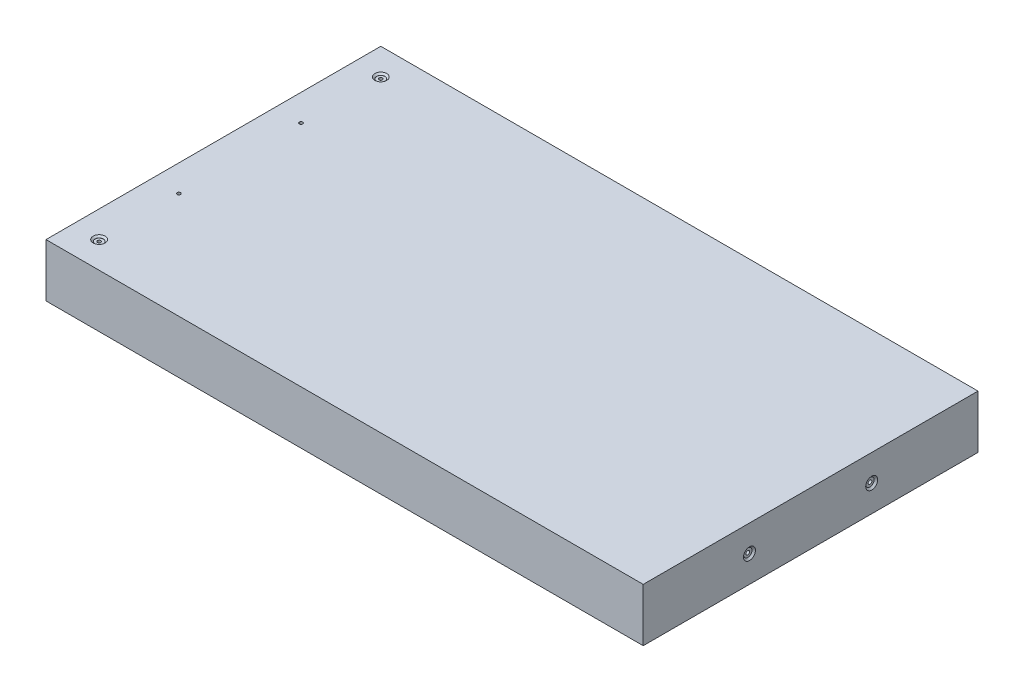
from build123d import *

# Parameters (mm, degrees)
SKETCH1_W                                   = 285.4
SKETCH1_H                                   = 160
BOSS_EXTRUDE1_DEPTH                         = 25.4
CBORE_FOR_0_BINDING_HEAD_MACHINE_SC_2_COUNT = 2
CBORE_FOR_0_BINDING_HEAD_MACHINE_SC_2_PITCH = 58.4
CBORE_FOR_0_BINDING_HEAD_MACHINE_SC_3_COUNT = 2
CBORE_FOR_0_BINDING_HEAD_MACHINE_SC_3_PITCH = 134.6
CBORE_FOR_0_BINDING_HEAD_MACHINE_SC_4_COUNT = 2
CBORE_FOR_0_BINDING_HEAD_MACHINE_SC_4_PITCH = 58.4


with BuildPart() as part:
    # Sketch1 → Boss-Extrude1 (new body)
    with BuildSketch(Plane(origin=(0, 0, 0), x_dir=(1, 0, 0), z_dir=(0, 1, 0))):
        Rectangle(SKETCH1_W, SKETCH1_H)
    extrude(amount=BOSS_EXTRUDE1_DEPTH)

    # Sketch3 → CBORE for #0 Binding Head Machine Screw3 (revolve, cut)
    with BuildSketch(Plane(origin=(142.7, 12.7, 29.2), x_dir=(0, 0, -1), z_dir=(0, 1, 0))):
        Polygon((0, 0), (0, 30.53416509), (0.889, 30), (0.889, 0.8128), (1.98501, 0.8128), (1.98501, 0.87249), (2.8575, 0), align=None)
    cbore_for_0_binding_head_machine_screw3 = revolve(axis=Axis((149.05, 12.7, 29.2), (-1, 0, 0)), mode=Mode.SUBTRACT)

    # CBORE for _0 Binding Head Machine Sc 2: CBORE for #0 Binding Head Machine Screw3 ×2
    with Locations(*[(0, 0, -i * CBORE_FOR_0_BINDING_HEAD_MACHINE_SC_2_PITCH) for i in range(1, CBORE_FOR_0_BINDING_HEAD_MACHINE_SC_2_COUNT)]):
        add(cbore_for_0_binding_head_machine_screw3, mode=Mode.SUBTRACT)

    # Sketch7 → CBORE for #0 Binding Head Machine Screw1 (revolve, cut)
    with BuildSketch(Plane(origin=(-130, 25.4, 67.3), x_dir=(0, 0, 1), z_dir=(1, 0, 0))):
        Polygon((0, 0), (0, 25.4), (0.80645, 25.4), (0.80645, 0.8128), (1.98501, 0.8128), (1.98501, 0.732106037), (2.8575, 0), align=None)
    cbore_for_0_binding_head_machine_screw1 = revolve(axis=Axis((-130, 31.75, 67.3), (0, -1, 0)), mode=Mode.SUBTRACT)

    # CBORE for _0 Binding Head Machine Sc 3: CBORE for #0 Binding Head Machine Screw1 ×2
    with Locations(*[(0, 0, -i * CBORE_FOR_0_BINDING_HEAD_MACHINE_SC_3_PITCH) for i in range(1, CBORE_FOR_0_BINDING_HEAD_MACHINE_SC_3_COUNT)]):
        add(cbore_for_0_binding_head_machine_screw1, mode=Mode.SUBTRACT)

    # Sketch9 → CBORE for #0 Binding Head Machine Screw2 (revolve, cut)
    with BuildSketch(Plane(origin=(-130, 0, -29.2), x_dir=(0, 0, -1), z_dir=(1, 0, 0))):
        Polygon((0, 0), (0, 25.4), (0.80645, 25.4), (0.80645, 0.8128), (1.98501, 0.8128), (1.98501, 0.732106037), (2.8575, 0), align=None)
    cbore_for_0_binding_head_machine_screw2 = revolve(axis=Axis((-130, -6.35, -29.2), (0, 1, 0)), mode=Mode.SUBTRACT)

    # CBORE for _0 Binding Head Machine Sc 4: CBORE for #0 Binding Head Machine Screw2 ×2
    with Locations(*[(0, 0, i * CBORE_FOR_0_BINDING_HEAD_MACHINE_SC_4_PITCH) for i in range(1, CBORE_FOR_0_BINDING_HEAD_MACHINE_SC_4_COUNT)]):
        add(cbore_for_0_binding_head_machine_screw2, mode=Mode.SUBTRACT)


solid = part.part
